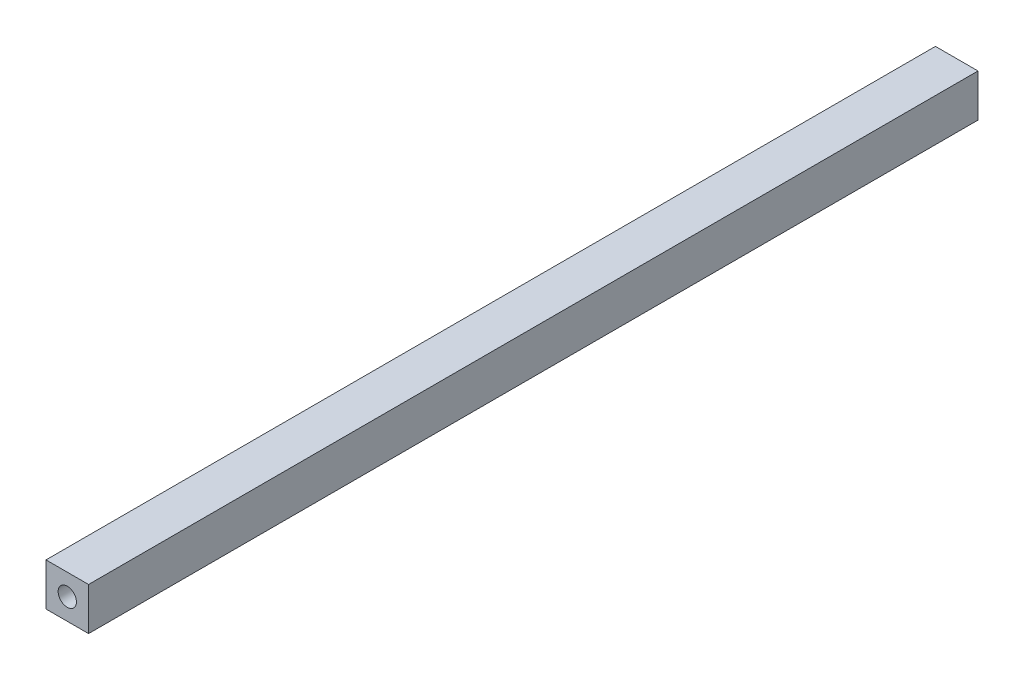
from build123d import *

# Parameters (mm, degrees)
IZIM1_W                     = 28
IZIM1_H                     = 28
Y_KSEKLIK_EKSTR_ZYON1_DEPTH = 585
IZIM2_R                     = 6
KES_EKSTR_ZYON1_DEPTH       = 60


with BuildPart() as part:
    # Çizim1 → Yükseklik-Ekstrüzyon1 (new body)
    with BuildSketch(Plane.XY):
        Rectangle(IZIM1_W, IZIM1_H)
    extrude(amount=Y_KSEKLIK_EKSTR_ZYON1_DEPTH)

    # Çizim2 → Kes-Ekstrüzyon1 (cut)
    with BuildSketch(Plane.XY.offset(585)):
        Circle(IZIM2_R)
    extrude(amount=-KES_EKSTR_ZYON1_DEPTH, mode=Mode.SUBTRACT)


solid = part.part
